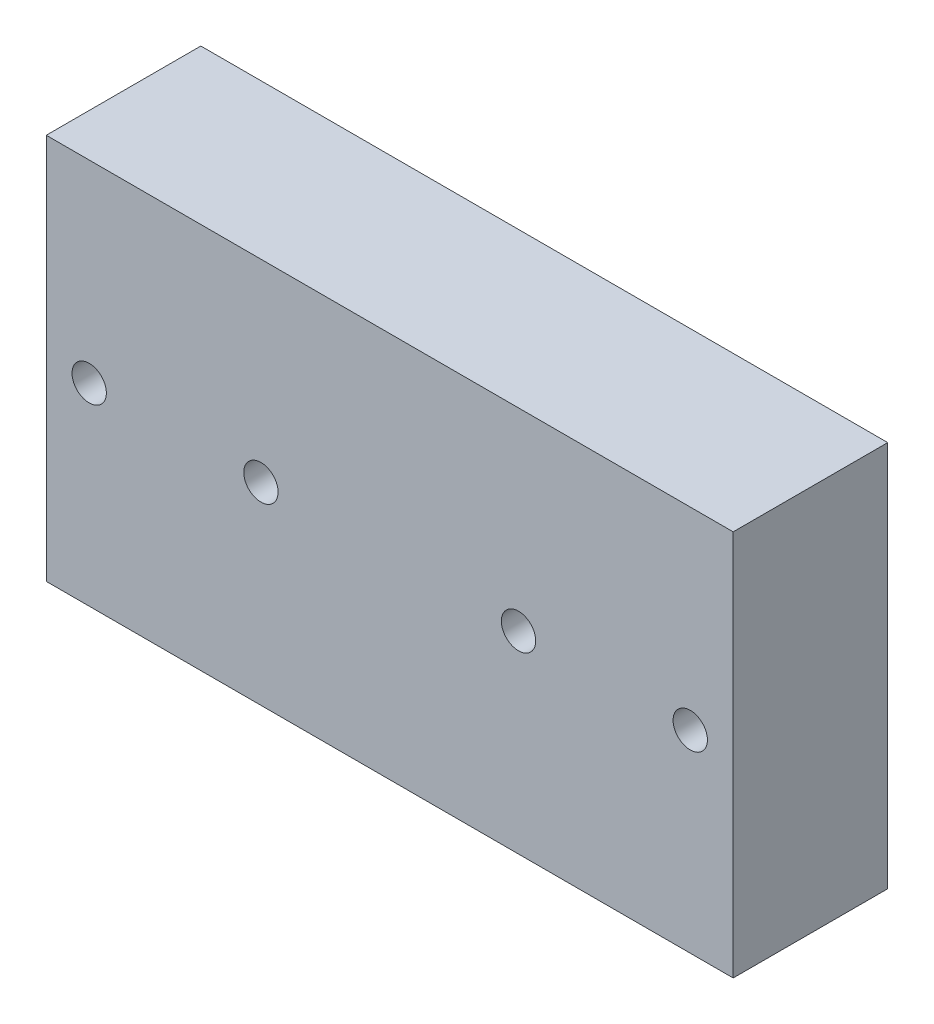
from build123d import *

# Parameters (mm, degrees)
SKETCH1_W           = 80
SKETCH1_H           = 45
SKETCH1_R           = 2
BOSS_EXTRUDE1_DEPTH = 18


with BuildPart() as part:
    # Sketch1 → Boss-Extrude1 (new body)
    with BuildSketch(Plane.XY):
        Rectangle(SKETCH1_W, SKETCH1_H)
        with Locations((35, 0)):
            Circle(SKETCH1_R, mode=Mode.SUBTRACT)
        with Locations((15, 0)):
            Circle(SKETCH1_R, mode=Mode.SUBTRACT)
        with Locations((-15, 0)):
            Circle(SKETCH1_R, mode=Mode.SUBTRACT)
        with Locations((-35, 0)):
            Circle(SKETCH1_R, mode=Mode.SUBTRACT)
    extrude(amount=BOSS_EXTRUDE1_DEPTH)


solid = part.part
